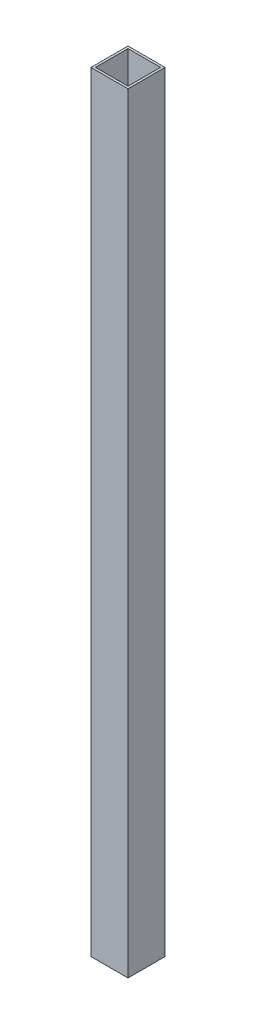
from build123d import *

# Parameters (mm, degrees)
SKETCH1_W           = 25.4
SKETCH1_H           = 25.4
SKETCH1_W_2         = 22.352
SKETCH1_H_2         = 22.352
BOSS_EXTRUDE1_DEPTH = 528.32


with BuildPart() as part:
    # Sketch1 → Boss-Extrude1 (new body)
    with BuildSketch(Plane(origin=(0, 0, 0), x_dir=(1, 0, 0), z_dir=(0, 1, 0))):
        with Locations((-20.6375, 6.746875)):
            Rectangle(SKETCH1_W, SKETCH1_H)
        with Locations((-20.6375, 6.746875)):
            Rectangle(SKETCH1_W_2, SKETCH1_H_2, mode=Mode.SUBTRACT)
    extrude(amount=BOSS_EXTRUDE1_DEPTH)


solid = part.part
